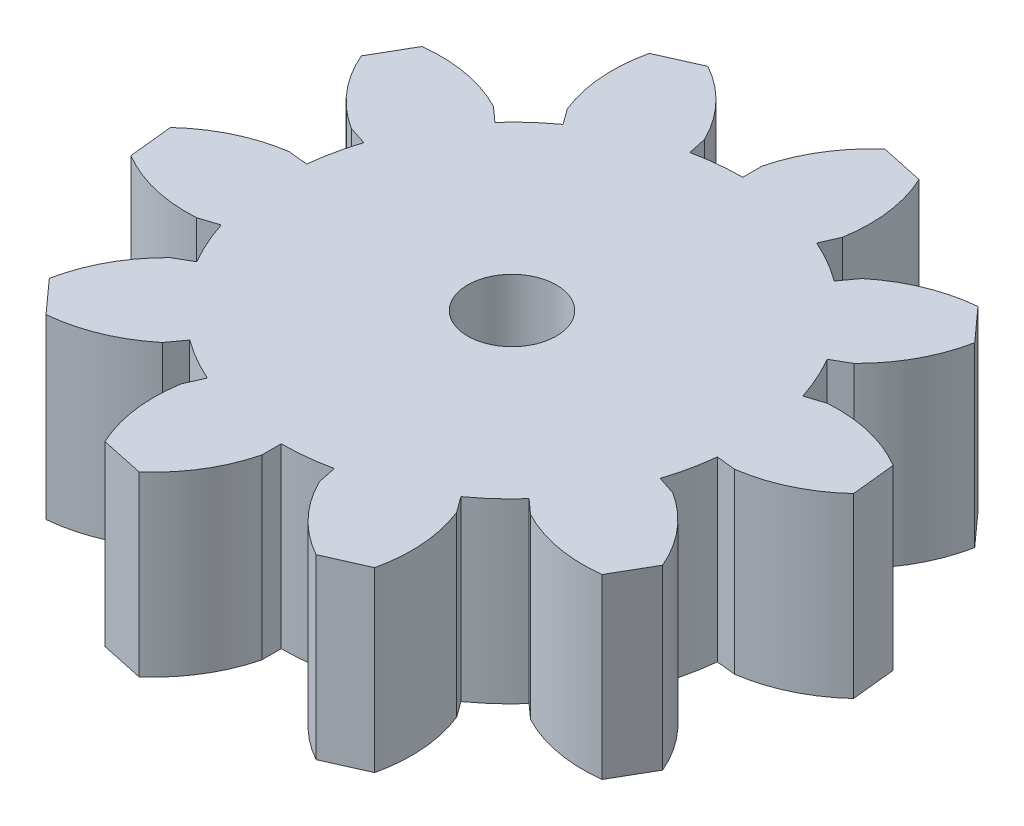
from build123d import *

# Parameters (mm, degrees)
BOSS_EXTRUDE2_DEPTH = 10
CIRPATTERN1_COUNT   = 10
SKETCH1_5_R         = 13
BOSS_EXTRUDE3_DEPTH = 10
SKETCH2_R           = 2.5
CUT_EXTRUDE1_DEPTH  = 28.962538453


with BuildPart() as part:
    # Sketch1 → Boss-Extrude2 (new body)
    with BuildSketch(Plane(origin=(0, 0, 0), x_dir=(1, 0, 0), z_dir=(0, 1, 0))):
        with BuildLine():
            ThreePointArc((2.628362747, 18.377642448), (0.987757529, 16.436868415), (0, 14.095389312))
            Line((0, 14.095389312), (0, 13))
            ThreePointArc((0, 13), (2.702851981, 12.71591881), (5.28757636, 11.876090949))
            Line((5.28757636, 11.876090949), (5.733111332, 12.876778879))
            ThreePointArc((5.733111332, 12.876778879), (5.783115278, 15.41758366), (5.073731749, 17.857863221))
            Line((5.073731749, 17.857863221), (2.628362747, 18.377642448))
        make_face()
    extrude(amount=BOSS_EXTRUDE2_DEPTH)


with BuildPart() as cirpattern1_1:
    # CirPattern1: pattern copy
    add(part.part.rotate(Axis((0, 10.5, 0), (0, -1, 0)), 1 * 360 / CIRPATTERN1_COUNT))


with BuildPart() as cirpattern1_2:
    # CirPattern1: pattern copy
    add(part.part.rotate(Axis((0, 10.5, 0), (0, -1, 0)), 2 * 360 / CIRPATTERN1_COUNT))


with BuildPart() as cirpattern1_3:
    # CirPattern1: pattern copy
    add(part.part.rotate(Axis((0, 10.5, 0), (0, -1, 0)), 3 * 360 / CIRPATTERN1_COUNT))


with BuildPart() as cirpattern1_4:
    # CirPattern1: pattern copy
    add(part.part.rotate(Axis((0, 10.5, 0), (0, -1, 0)), 4 * 360 / CIRPATTERN1_COUNT))


with BuildPart() as cirpattern1_5:
    # CirPattern1: pattern copy
    add(part.part.rotate(Axis((0, 10.5, 0), (0, -1, 0)), 5 * 360 / CIRPATTERN1_COUNT))


with BuildPart() as cirpattern1_6:
    # CirPattern1: pattern copy
    add(part.part.rotate(Axis((0, 10.5, 0), (0, -1, 0)), 6 * 360 / CIRPATTERN1_COUNT))


with BuildPart() as cirpattern1_7:
    # CirPattern1: pattern copy
    add(part.part.rotate(Axis((0, 10.5, 0), (0, -1, 0)), 7 * 360 / CIRPATTERN1_COUNT))


with BuildPart() as cirpattern1_8:
    # CirPattern1: pattern copy
    add(part.part.rotate(Axis((0, 10.5, 0), (0, -1, 0)), 8 * 360 / CIRPATTERN1_COUNT))


with BuildPart() as cirpattern1_9:
    # CirPattern1: pattern copy
    add(part.part.rotate(Axis((0, 10.5, 0), (0, -1, 0)), 9 * 360 / CIRPATTERN1_COUNT))


with BuildPart() as part_1:
    add(part.part)

    add(cirpattern1_1.part)  # Boss-Extrude3 merges CirPattern1_1

    add(cirpattern1_2.part)  # Boss-Extrude3 merges CirPattern1_2

    add(cirpattern1_3.part)  # Boss-Extrude3 merges CirPattern1_3

    add(cirpattern1_4.part)  # Boss-Extrude3 merges CirPattern1_4

    add(cirpattern1_5.part)  # Boss-Extrude3 merges CirPattern1_5

    add(cirpattern1_6.part)  # Boss-Extrude3 merges CirPattern1_6

    add(cirpattern1_7.part)  # Boss-Extrude3 merges CirPattern1_7

    add(cirpattern1_8.part)  # Boss-Extrude3 merges CirPattern1_8

    add(cirpattern1_9.part)  # Boss-Extrude3 merges CirPattern1_9
    # Sketch1_5 → Boss-Extrude3 (add)
    with BuildSketch(Plane(origin=(0, 0, 0), x_dir=(1, 0, 0), z_dir=(0, 1, 0))):
        Circle(SKETCH1_5_R)
    extrude(amount=BOSS_EXTRUDE3_DEPTH)

    # Sketch2 → Cut-Extrude1 (cut, through all)
    with BuildSketch(Plane.XZ):
        Circle(SKETCH2_R)
    extrude(amount=-CUT_EXTRUDE1_DEPTH, mode=Mode.SUBTRACT)


solid = part_1.part
